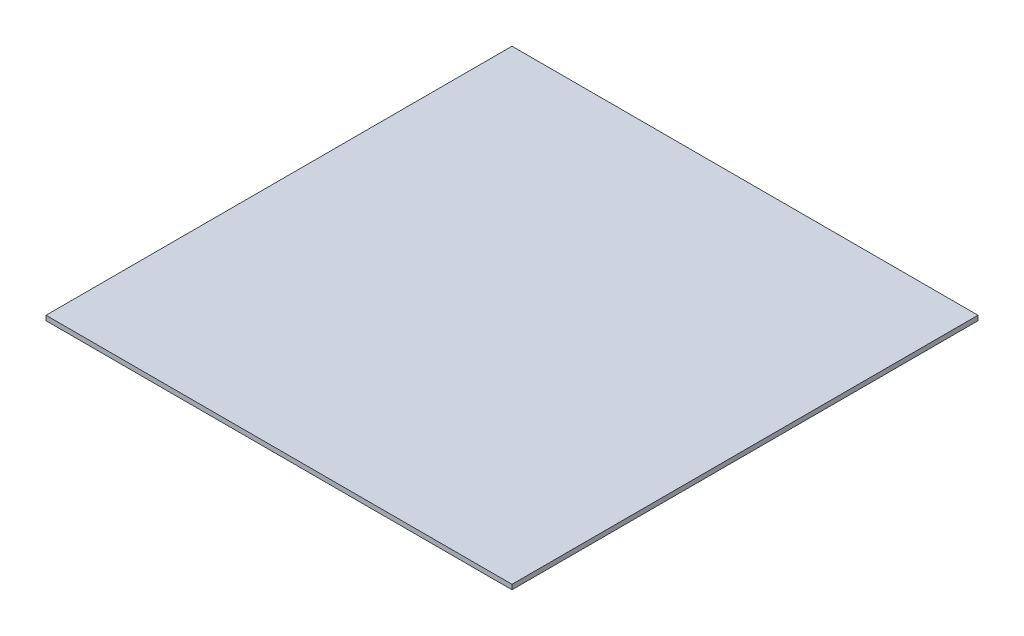
from build123d import *

# Parameters (mm, degrees)
SKETCH1_W           = 292.1
SKETCH1_H           = 292.1
BOSS_EXTRUDE1_DEPTH = 3


with BuildPart() as part:
    # Sketch1 → Boss-Extrude1 (new body)
    with BuildSketch(Plane(origin=(0, 0, 0), x_dir=(1, 0, 0), z_dir=(0, 1, 0))):
        Rectangle(SKETCH1_W, SKETCH1_H)
    extrude(amount=BOSS_EXTRUDE1_DEPTH)


solid = part.part
